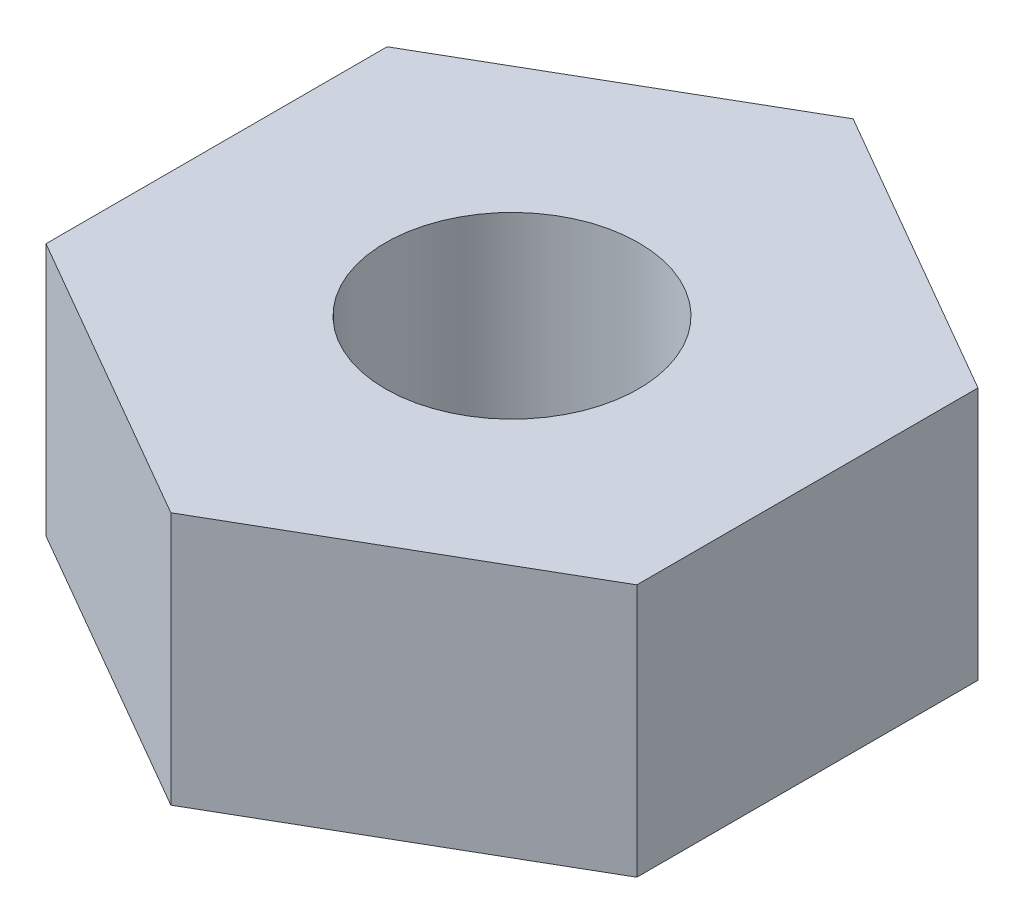
from build123d import *

# Parameters (mm, degrees)
SALIENTE_EXTRUIR1_DEPTH = 3
CROQUIS3_R              = 1.5
CORTAR_EXTRUIR1_DEPTH   = 5.5


with BuildPart() as part:
    # Croquis1 → Saliente-Extruir1 (new body)
    with BuildSketch(Plane(origin=(0, 0, 0), x_dir=(1, 0, 0), z_dir=(0, 1, 0))):
        Polygon((0, 4.041451884), (-3.5, 2.020725942), (-3.5, -2.020725942), (0, -4.041451884), (3.5, -2.020725942), (3.5, 2.020725942), align=None)
    extrude(amount=SALIENTE_EXTRUIR1_DEPTH)

    # Croquis3 → Cortar-Extruir1 (cut)
    with BuildSketch(Plane(origin=(0, 3, 0), x_dir=(1, 0, 0), z_dir=(0, 1, 0))):
        Circle(CROQUIS3_R)
    extrude(amount=-CORTAR_EXTRUIR1_DEPTH, mode=Mode.SUBTRACT)


solid = part.part
